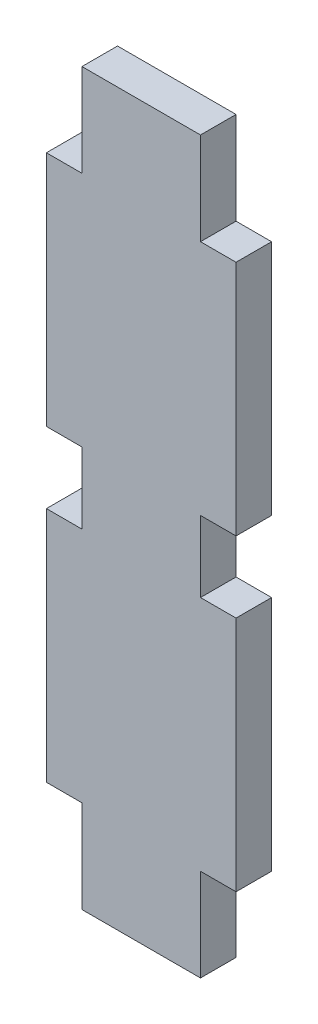
from build123d import *

# Parameters (mm, degrees)
BOSS_EXTRUDE1_DEPTH = 3


with BuildPart() as part:
    # Sketch1 → Boss-Extrude1 (new body)
    with BuildSketch(Plane.XY):
        Polygon((3, -428.2), (13, -428.2), (13, -436), (16, -436), (16, -456), (13, -456), (13, -462), (16, -462), (16, -482), (13, -482), (13, -489.8), (3, -489.8), (3, -482), (0, -482), (0, -462), (3, -462), (3, -456), (0, -456), (0, -436), (3, -436), align=None)
    extrude(amount=BOSS_EXTRUDE1_DEPTH)


solid = part.part
